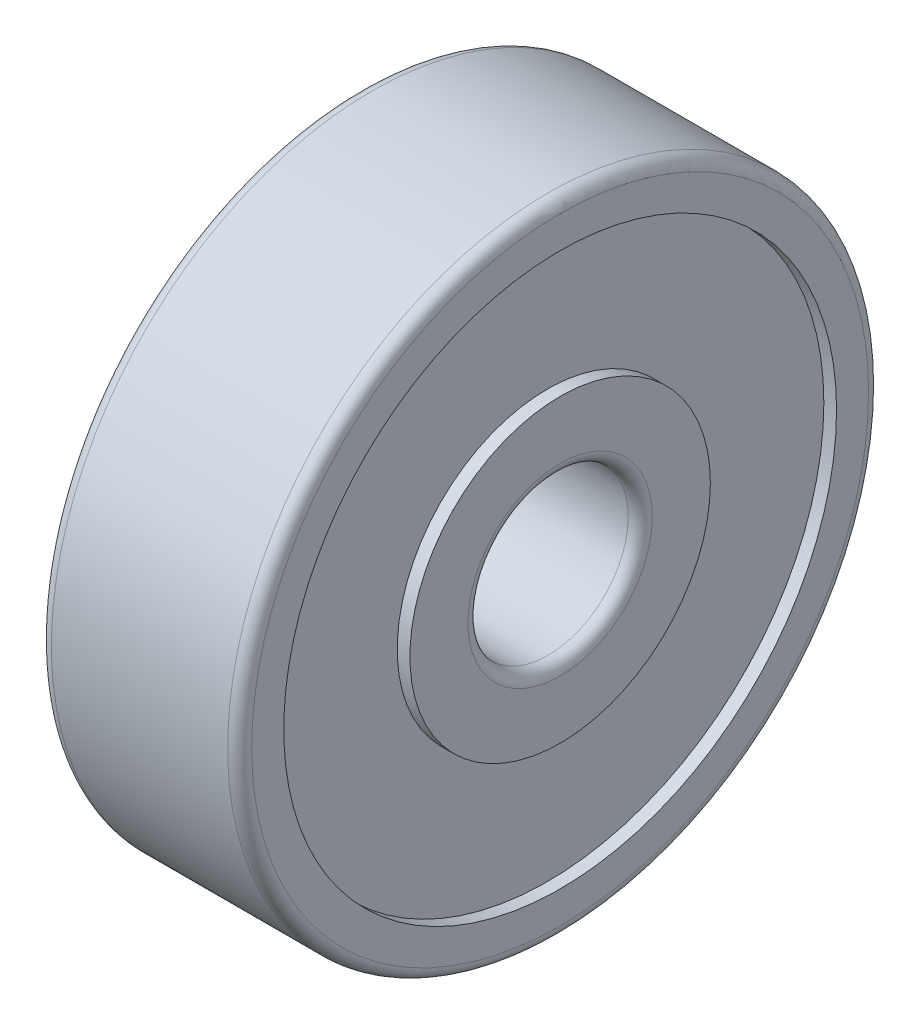
from build123d import *


with BuildPart() as part:
    # Sketch1 → Revolve1 (revolve)
    with BuildSketch(Plane.XY):
        with BuildLine():
            Line((0, 3.75), (0, 2.3))
            ThreePointArc((0, 2.3), (0.087867966, 2.087867966), (0.3, 2))
            Line((0.3, 2), (4.7, 2))
            ThreePointArc((4.7, 2), (4.912132034, 2.087867966), (5, 2.3))
            Line((5, 2.3), (5, 3.75))
            Line((5, 3.75), (4.683, 3.75))
            Line((4.683, 3.75), (4.683, 6.9))
            Line((4.683, 6.9), (5, 6.9))
            Line((5, 6.9), (5, 7.7))
            ThreePointArc((5, 7.7), (4.912132034, 7.912132034), (4.7, 8))
            Line((4.7, 8), (0.3, 8))
            ThreePointArc((0.3, 8), (0.087867966, 7.912132034), (0, 7.7))
            Line((0, 7.7), (0, 6.9))
            Line((0, 6.9), (0.317, 6.9))
            Line((0.317, 6.9), (0.317, 3.75))
            Line((0.317, 3.75), (0, 3.75))
        make_face()
    revolve(axis=Axis((-0.001355266, 0, 0), (1, 0, 0)))


solid = part.part
